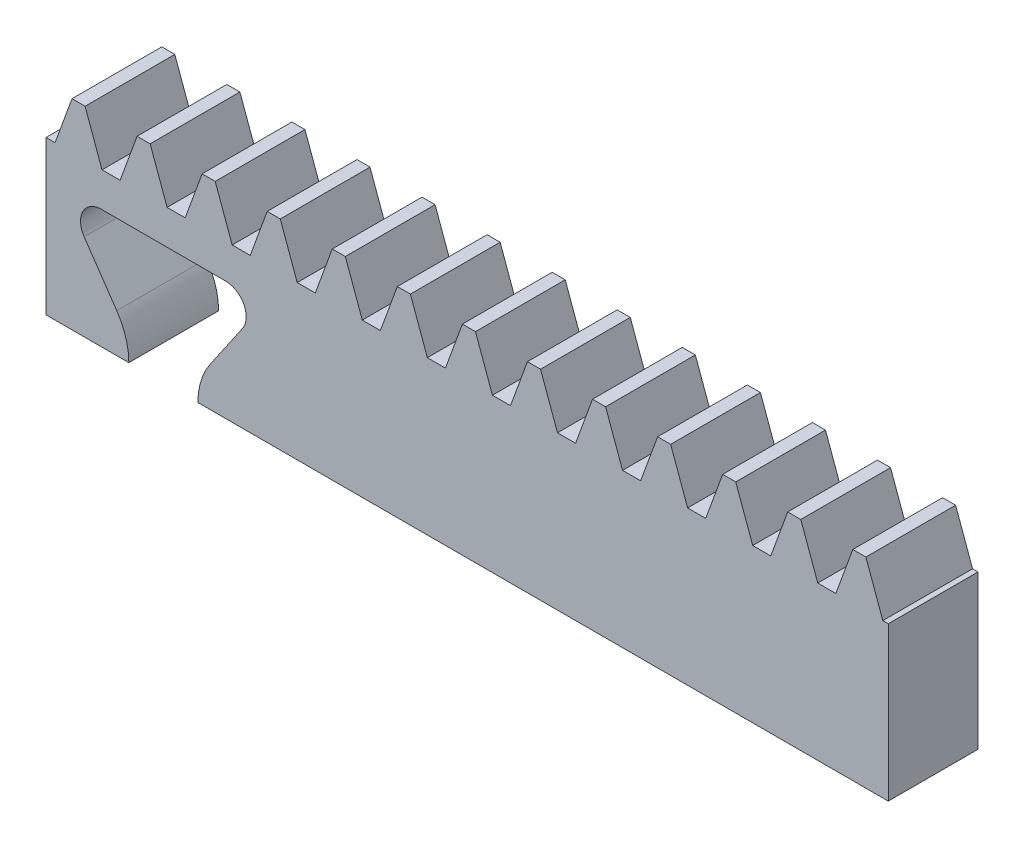
from build123d import *

# Parameters (mm, degrees)
BLANKSKE_W        = 61
BLANKSKE_H        = 14.5
BLANK_DEPTH       = 6.5
TOOTHCUTSIM_DEPTH = 64.035704168
TEETHCUTS_COUNT   = 14
TEETHCUTS_PITCH   = 4.712388975
DOVETAIL_DEPTH    = 6.5


with BuildPart() as part:
    # BlankSke → Blank (new body)
    with BuildSketch(Plane.XY):
        with Locations((30.5, 7.25)):
            Rectangle(BLANKSKE_W, BLANKSKE_H)
    extrude(amount=-BLANK_DEPTH)

    # TooCutSkeSim → ToothCutSim (cut, through all)
    with BuildSketch(Plane.XY):
        Polygon((0.654653055, 11.125), (-0.654653055, 11.125), (-1.892297439, 14.5254), (1.892297439, 14.5254), align=None)
    toothcutsim = extrude(amount=-TOOTHCUTSIM_DEPTH, mode=Mode.SUBTRACT)

    # TeethCuts: ToothCutSim ×14
    with Locations(*[(i * TEETHCUTS_PITCH, 0, 0) for i in range(1, TEETHCUTS_COUNT)]):
        add(toothcutsim, mode=Mode.SUBTRACT)

    # Sketch2 → Dovetail (cut)
    with BuildSketch(Plane.XY):
        with BuildLine():
            Line((13, 8.625), (4, 8.625))
            ThreePointArc((4, 8.625), (2.673189596, 7.824695756), (2.762181855, 6.277765535))
            Line((2.762181855, 6.277765535), (5.126060485, 2.824114884))
            ThreePointArc((5.126060485, 2.824114884), (5.776520827, 1.478123401), (6, 0))
            Line((6, 0), (11, 0))
            ThreePointArc((11, 0), (11.223479173, 1.478123401), (11.873939515, 2.824114884))
            Line((11.873939515, 2.824114884), (14.237818145, 6.277765535))
            ThreePointArc((14.237818145, 6.277765535), (14.326810404, 7.824695756), (13, 8.625))
        make_face()
    extrude(amount=-DOVETAIL_DEPTH, mode=Mode.SUBTRACT)


solid = part.part
